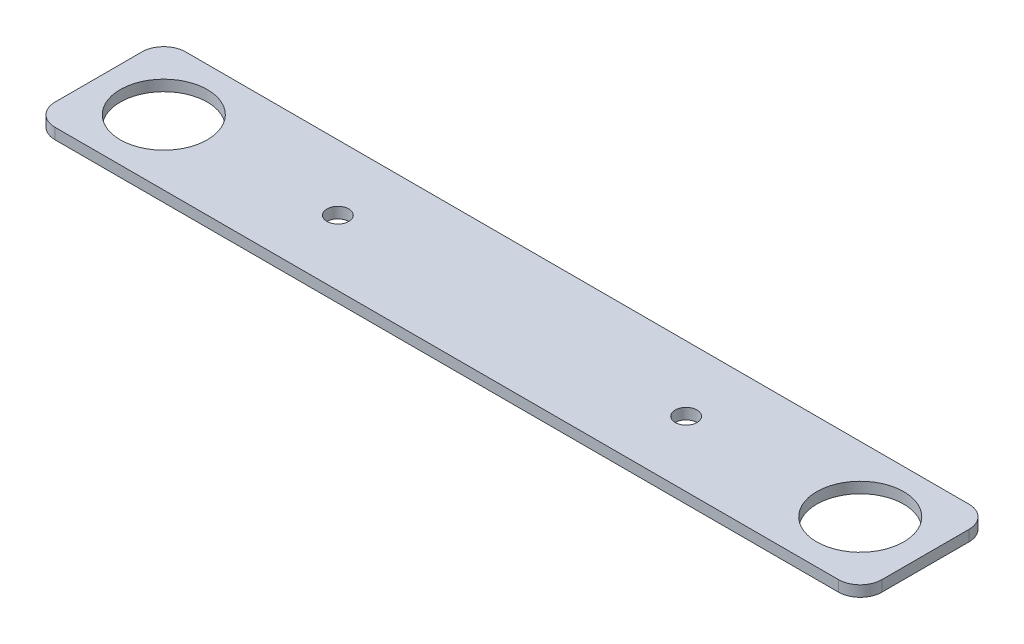
from build123d import *

# Parameters (mm, degrees)
SKETCH1_R           = 12.7
SKETCH1_R_2         = 3.175
BOSS_EXTRUDE1_DEPTH = 3.175


with BuildPart() as part:
    # Sketch1 → Boss-Extrude1 (new body)
    with BuildSketch(Plane(origin=(0, 0, 0), x_dir=(1, 0, 0), z_dir=(0, 1, 0))):
        with BuildLine():
            Line((-12.7, -19.05), (215.9, -19.05))
            ThreePointArc((215.9, -19.05), (220.390128061, -17.190128061), (222.25, -12.7))
            Line((222.25, -12.7), (222.25, 12.7))
            ThreePointArc((222.25, 12.7), (220.390128061, 17.190128061), (215.9, 19.05))
            Line((215.9, 19.05), (-12.7, 19.05))
            ThreePointArc((-12.7, 19.05), (-17.190128061, 17.190128061), (-19.05, 12.7))
            Line((-19.05, 12.7), (-19.05, -12.7))
            ThreePointArc((-19.05, -12.7), (-17.190128061, -17.190128061), (-12.7, -19.05))
        make_face()
        Circle(SKETCH1_R, mode=Mode.SUBTRACT)
        with Locations((203.2, 0)):
            Circle(SKETCH1_R, mode=Mode.SUBTRACT)
        with Locations((50.8, 0)):
            Circle(SKETCH1_R_2, mode=Mode.SUBTRACT)
        with Locations((152.4, 0)):
            Circle(SKETCH1_R_2, mode=Mode.SUBTRACT)
    extrude(amount=BOSS_EXTRUDE1_DEPTH)


solid = part.part
